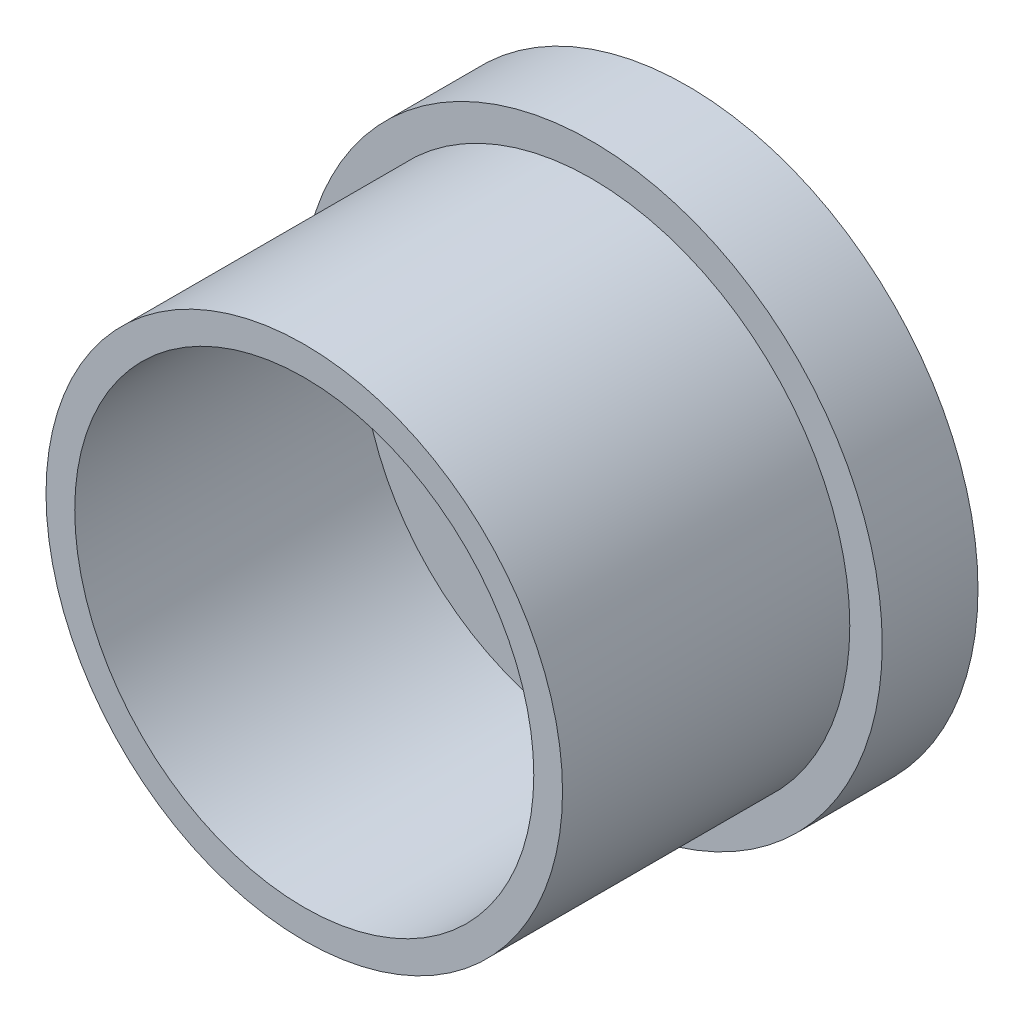
from build123d import *

# Parameters (mm, degrees)
SKETCH3_R           = 30.358351357
BOSS_EXTRUDE2_DEPTH = 10
SKETCH4_R           = 26.969977479
SKETCH4_R_2         = 23.969977479
BOSS_EXTRUDE3_DEPTH = 30


with BuildPart() as part:
    # Sketch3 → Boss-Extrude2 (new body)
    with BuildSketch(Plane.XY):
        with Locations((-22.75, 10.5)):
            Circle(SKETCH3_R)
        with BuildLine():
            ThreePointArc((-35, 1.680276087), (-43.819723913, 10.5), (-35, 19.319723913))
            Line((-35, 19.319723913), (-28.378131485, 19.319723913))
            Line((-28.378131485, 19.319723913), (-28.378131485, 21))
            Line((-28.378131485, 21), (-17.074172485, 21))
            Line((-17.074172485, 21), (-17.074172485, 19.319723913))
            Line((-17.074172485, 19.319723913), (-10.5, 19.319723913))
            ThreePointArc((-10.5, 19.319723913), (-1.680276087, 10.5), (-10.5, 1.680276087))
            Line((-10.5, 1.680276087), (-16.75, 1.680276087))
            Line((-16.75, 1.680276087), (-16.75, 0))
            Line((-16.75, 0), (-28.75, 0))
            Line((-28.75, 0), (-28.75, 1.680276087))
            Line((-28.75, 1.680276087), (-35, 1.680276087))
        make_face(mode=Mode.SUBTRACT)
    extrude(amount=BOSS_EXTRUDE2_DEPTH)

    # Sketch4 → Boss-Extrude3 (add)
    with BuildSketch(Plane.XY.offset(10)):
        with Locations((-22.75, 10.5)):
            Circle(SKETCH4_R)
        with Locations((-22.75, 10.5)):
            Circle(SKETCH4_R_2, mode=Mode.SUBTRACT)
    extrude(amount=BOSS_EXTRUDE3_DEPTH)


solid = part.part
